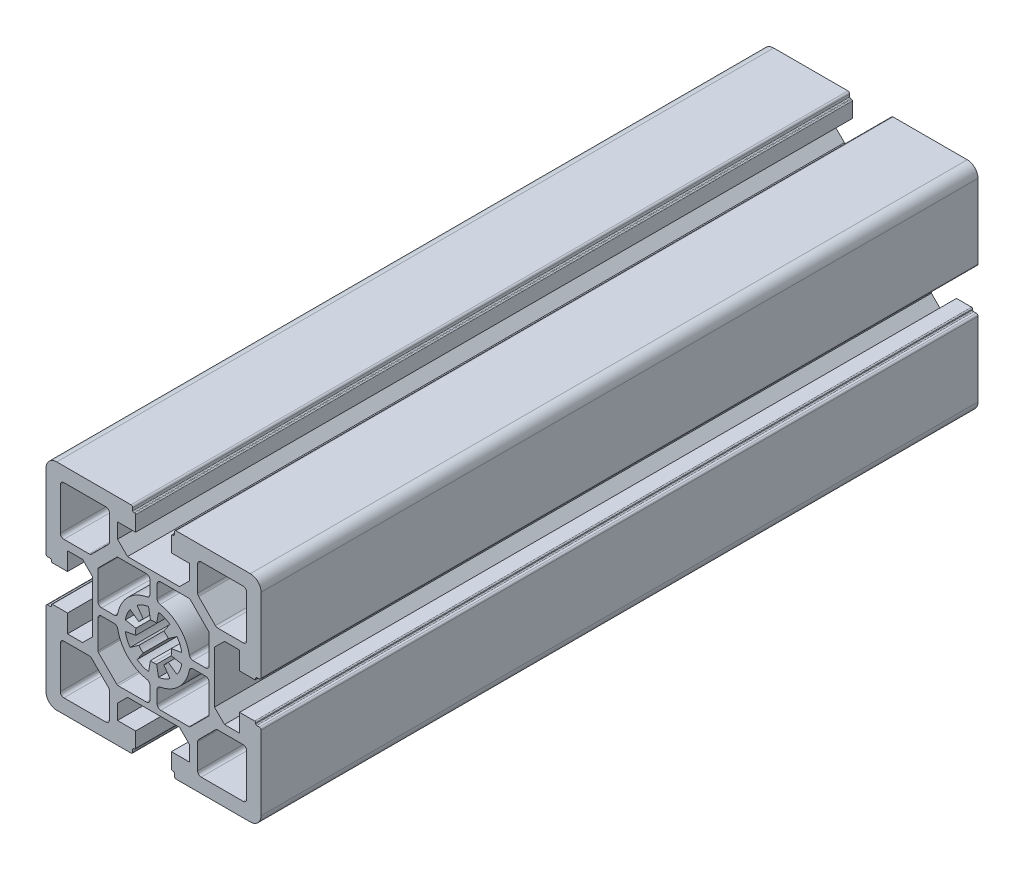
from build123d import *

# Parameters (mm, degrees)
BASE_EXTRUDE_DEPTH = 200


with BuildPart() as part:
    # Sketch1 → Base-Extrude (new body)
    with BuildSketch(Plane.XY):
        with BuildLine():
            Line((7.24997588, 17.000014817), (-2.412e-05, 17.000014817))
            Line((-2.412e-05, 17.000014817), (-7.25002412, 17.000014817))
            Line((-7.25002412, 17.000014817), (-10.05002512, 19.800013819))
            Line((-10.05002512, 19.800013819), (-10.05002512, 24.000014819))
            Line((-10.05002512, 24.000014819), (-5.00002412, 24.000014819))
            Line((-5.00002412, 24.000014819), (-5.00002412, 28.200020635))
            ThreePointArc((-5.00002412, 28.200020635), (-5.087890425, 28.412148621), (-5.300018455, 28.500014819))
            Line((-5.300018455, 28.500014819), (-5.500021455, 28.500014819))
            ThreePointArc((-5.500021455, 28.500014819), (-5.712152769, 28.587882347), (-5.800020455, 28.800013596))
            Line((-5.800020455, 28.800013596), (-5.800020455, 29.500015192))
            ThreePointArc((-5.800020455, 29.500015192), (-5.946466955, 29.853568318), (-6.300020081, 30.000014817))
            Line((-6.300020081, 30.000014817), (-27.000022696, 30.000014817))
            ThreePointArc((-27.000022696, 30.000014817), (-29.121341455, 29.121335817), (-30.000020455, 27.000017059))
            Line((-30.000020455, 27.000017059), (-30.000020455, 6.300013444))
            ThreePointArc((-30.000020455, 6.300013444), (-29.853573955, 5.946460317), (-29.500020828, 5.800013817))
            Line((-29.500020828, 5.800013817), (-28.800019731, 5.800013817))
            ThreePointArc((-28.800019731, 5.800013817), (-28.587888208, 5.712146064), (-28.500020455, 5.500014542))
            Line((-28.500020455, 5.500014542), (-28.500020455, 5.300014093))
            ThreePointArc((-28.500020455, 5.300014093), (-28.412152701, 5.087882571), (-28.200021179, 5.000014817))
            Line((-28.200021179, 5.000014817), (-24.000020455, 5.000014817))
            Line((-24.000020455, 5.000014817), (-24.000020455, 10.050012866))
            Line((-24.000020455, 10.050012866), (-19.800019665, 10.050012866))
            Line((-19.800019665, 10.050012866), (-17.000019665, 7.250013866))
            Line((-17.000019665, 7.250013866), (-17.000019665, 4.3167e-05))
            Line((-17.000019665, 4.3167e-05), (-17.000019665, -7.249956831))
            Line((-17.000019665, -7.249956831), (-19.800019665, -10.049955831))
            Line((-19.800019665, -10.049955831), (-24.000020455, -10.049955831))
            Line((-24.000020455, -10.049955831), (-24.000020455, -4.999957783))
            Line((-24.000020455, -4.999957783), (-28.200021179, -4.999957783))
            ThreePointArc((-28.200021179, -4.999957783), (-28.412152701, -5.087825536), (-28.500020455, -5.299957058))
            Line((-28.500020455, -5.299957058), (-28.500020455, -5.499957507))
            ThreePointArc((-28.500020455, -5.499957507), (-28.587888208, -5.712089029), (-28.800019731, -5.799956783))
            Line((-28.800019731, -5.799956783), (-29.500020828, -5.799956783))
            ThreePointArc((-29.500020828, -5.799956783), (-29.853573955, -5.946403283), (-30.000020455, -6.299956409))
            Line((-30.000020455, -6.299956409), (-30.000020455, -26.999960024))
            ThreePointArc((-30.000020455, -26.999960024), (-29.121341455, -29.121278783), (-27.000022696, -29.999957783))
            Line((-27.000022696, -29.999957783), (-6.300020081, -29.999957783))
            ThreePointArc((-6.300020081, -29.999957783), (-5.946466955, -29.853511283), (-5.800020455, -29.499958157))
            Line((-5.800020455, -29.499958157), (-5.800020455, -28.799956561))
            ThreePointArc((-5.800020455, -28.799956561), (-5.712152769, -28.587825312), (-5.500021455, -28.499957784))
            Line((-5.500021455, -28.499957784), (-5.300018455, -28.499957784))
            ThreePointArc((-5.300018455, -28.499957784), (-5.087890425, -28.412091586), (-5.00002412, -28.199963601))
            Line((-5.00002412, -28.199963601), (-5.00002412, -23.999957784))
            Line((-5.00002412, -23.999957784), (-10.05002512, -23.999957784))
            Line((-10.05002512, -23.999957784), (-10.05002512, -19.799956784))
            Line((-10.05002512, -19.799956784), (-7.25002412, -16.999957783))
            Line((-7.25002412, -16.999957783), (-2.412e-05, -16.999957783))
            Line((-2.412e-05, -16.999957783), (7.24997588, -16.999957783))
            Line((7.24997588, -16.999957783), (10.04997688, -19.799956784))
            Line((10.04997688, -19.799956784), (10.04997688, -23.999957784))
            Line((10.04997688, -23.999957784), (4.99997588, -23.999957784))
            Line((4.99997588, -23.999957784), (4.99997588, -28.199963601))
            ThreePointArc((4.99997588, -28.199963601), (5.087842185, -28.412091586), (5.299970215, -28.499957784))
            Line((5.299970215, -28.499957784), (5.499973215, -28.499957784))
            ThreePointArc((5.499973215, -28.499957784), (5.71210453, -28.587825312), (5.799972216, -28.799956561))
            Line((5.799972216, -28.799956561), (5.799972216, -29.499958157))
            ThreePointArc((5.799972216, -29.499958157), (5.946418716, -29.853511283), (6.299971842, -29.999957783))
            Line((6.299971842, -29.999957783), (26.999974457, -29.999957783))
            ThreePointArc((26.999974457, -29.999957783), (29.121293215, -29.121278783), (29.999972215, -26.999960024))
            Line((29.999972215, -26.999960024), (29.999972215, -6.299956409))
            ThreePointArc((29.999972215, -6.299956409), (29.853525715, -5.946403283), (29.499972589, -5.799956783))
            Line((29.499972589, -5.799956783), (28.799971491, -5.799956783))
            ThreePointArc((28.799971491, -5.799956783), (28.587839969, -5.712089029), (28.499972215, -5.499957507))
            Line((28.499972215, -5.499957507), (28.499972215, -5.299957058))
            ThreePointArc((28.499972215, -5.299957058), (28.412104462, -5.087825536), (28.199972939, -4.999957783))
            Line((28.199972939, -4.999957783), (23.999972215, -4.999957783))
            Line((23.999972215, -4.999957783), (23.999972215, -10.049955831))
            Line((23.999972215, -10.049955831), (19.799971426, -10.049955831))
            Line((19.799971426, -10.049955831), (16.999971426, -7.249956831))
            Line((16.999971426, -7.249956831), (16.999971426, 4.3167e-05))
            Line((16.999971426, 4.3167e-05), (16.999971426, 7.250013866))
            Line((16.999971426, 7.250013866), (19.799971426, 10.050012866))
            Line((19.799971426, 10.050012866), (23.999972215, 10.050012866))
            Line((23.999972215, 10.050012866), (23.999972215, 5.000014817))
            Line((23.999972215, 5.000014817), (28.199972939, 5.000014817))
            ThreePointArc((28.199972939, 5.000014817), (28.412104462, 5.087882571), (28.499972215, 5.300014093))
            Line((28.499972215, 5.300014093), (28.499972215, 5.500014542))
            ThreePointArc((28.499972215, 5.500014542), (28.587839969, 5.712146064), (28.799971491, 5.800013817))
            Line((28.799971491, 5.800013817), (29.499972589, 5.800013817))
            ThreePointArc((29.499972589, 5.800013817), (29.853525715, 5.946460317), (29.999972215, 6.300013444))
            Line((29.999972215, 6.300013444), (29.999972215, 27.000017059))
            ThreePointArc((29.999972215, 27.000017059), (29.121293215, 29.121335817), (26.999974457, 30.000014817))
            Line((26.999974457, 30.000014817), (6.299971842, 30.000014817))
            ThreePointArc((6.299971842, 30.000014817), (5.946418716, 29.853568318), (5.799972216, 29.500015192))
            Line((5.799972216, 29.500015192), (5.799972216, 28.800013596))
            ThreePointArc((5.799972216, 28.800013596), (5.71210453, 28.587882347), (5.499973215, 28.500014819))
            Line((5.499973215, 28.500014819), (5.299970215, 28.500014819))
            ThreePointArc((5.299970215, 28.500014819), (5.087842185, 28.412148621), (4.99997588, 28.200020635))
            Line((4.99997588, 28.200020635), (4.99997588, 24.000014819))
            Line((4.99997588, 24.000014819), (10.04997688, 24.000014819))
            Line((10.04997688, 24.000014819), (10.04997688, 19.800013819))
            Line((10.04997688, 19.800013819), (7.24997588, 17.000014817))
        make_face()
        with BuildLine():
            Line((24.999970687, 12.300015508), (17.964182773, 12.300015508))
            ThreePointArc((17.964182773, 12.300015508), (17.581498992, 12.376136067), (17.257075378, 12.59290907))
            Line((17.257075378, 12.59290907), (12.592863552, 17.257122896))
            ThreePointArc((12.592863552, 17.257122896), (12.376090508, 17.581546796), (12.29996994, 17.964230842))
            Line((12.29996994, 17.964230842), (12.29996994, 25.000017255))
            ThreePointArc((12.29996994, 25.000017255), (12.59286294, 25.707123508), (13.299969193, 26.000016508))
            Line((13.299969193, 26.000016508), (24.999970687, 26.000016508))
            ThreePointArc((24.999970687, 26.000016508), (25.70707694, 25.707123508), (25.99996994, 25.000017255))
            Line((25.99996994, 25.000017255), (25.99996994, 13.300014761))
            ThreePointArc((25.99996994, 13.300014761), (25.70707694, 12.592908508), (24.999970687, 12.300015508))
        make_face(mode=Mode.SUBTRACT)
        with BuildLine():
            Line((-0.868254781, 4.924047323), (-1.389203942, 7.878492919))
            ThreePointArc((-1.389203942, 7.878492919), (-3.061491097, 7.391065963), (-4.588639176, 6.553242527))
            Line((-4.588639176, 6.553242527), (-2.867900032, 4.095774325))
            ThreePointArc((-2.867900032, 4.095774325), (-3.535545186, 3.535556326), (-4.095767305, 2.867914629))
            Line((-4.095767305, 2.867914629), (-6.553231573, 4.588649719))
            ThreePointArc((-6.553231573, 4.588649719), (-7.391053065, 3.061505388), (-7.878479822, 1.389222571))
            Line((-7.878479822, 1.389222571), (-4.924052211, 0.868276934))
            ThreePointArc((-4.924052211, 0.868276934), (-5.000015145, 2.8517e-05), (-4.924052211, -0.8682199))
            Line((-4.924052211, -0.8682199), (-7.878479822, -1.389165536))
            ThreePointArc((-7.878479822, -1.389165536), (-7.391053065, -3.061448353), (-6.553231573, -4.588592684))
            Line((-6.553231573, -4.588592684), (-4.095767305, -2.867857594))
            ThreePointArc((-4.095767305, -2.867857594), (-3.535545186, -3.535499291), (-2.867900032, -4.09571729))
            Line((-2.867900032, -4.09571729), (-4.588639176, -6.553185492))
            ThreePointArc((-4.588639176, -6.553185492), (-3.061491097, -7.391008929), (-1.389203942, -7.878435884))
            Line((-1.389203942, -7.878435884), (-0.868254781, -4.923990288))
            ThreePointArc((-0.868254781, -4.923990288), (-0.435797618, -4.980922606), (-2.412e-05, -4.999947433))
            ThreePointArc((-2.412e-05, -4.999947433), (0.435749379, -4.980922606), (0.868206541, -4.923990288))
            Line((0.868206541, -4.923990288), (1.389155702, -7.878435884))
            ThreePointArc((1.389155702, -7.878435884), (3.061442857, -7.391008929), (4.588590936, -6.553185492))
            Line((4.588590936, -6.553185492), (2.867851793, -4.09571729))
            ThreePointArc((2.867851793, -4.09571729), (3.535496947, -3.535499291), (4.095719065, -2.867857594))
            Line((4.095719065, -2.867857594), (6.553183334, -4.588592684))
            ThreePointArc((6.553183334, -4.588592684), (7.391004826, -3.061448353), (7.878431582, -1.389165536))
            Line((7.878431582, -1.389165536), (4.924003972, -0.8682199))
            ThreePointArc((4.924003972, -0.8682199), (4.999966905, 2.8517e-05), (4.924003972, 0.868276934))
            Line((4.924003972, 0.868276934), (7.878431582, 1.389222571))
            ThreePointArc((7.878431582, 1.389222571), (7.391004826, 3.061505388), (6.553183334, 4.588649719))
            Line((6.553183334, 4.588649719), (4.095719065, 2.867914629))
            ThreePointArc((4.095719065, 2.867914629), (3.535496947, 3.535556326), (2.867851793, 4.095774325))
            Line((2.867851793, 4.095774325), (4.588590936, 6.553242527))
            ThreePointArc((4.588590936, 6.553242527), (3.061442857, 7.391065963), (1.389155702, 7.878492919))
            Line((1.389155702, 7.878492919), (0.868206541, 4.924047323))
            ThreePointArc((0.868206541, 4.924047323), (0.435749379, 4.980979641), (-2.412e-05, 5.000004467))
            ThreePointArc((-2.412e-05, 5.000004467), (-0.435797618, 4.980979641), (-0.868254781, 4.924047323))
        make_face(mode=Mode.SUBTRACT)
        with BuildLine():
            Line((14.499970687, 1.000016508), (10.969128525, 1.000016508))
            ThreePointArc((10.969128525, 1.000016508), (10.328572063, 1.232105996), (9.985348997, 1.820643198))
            ThreePointArc((9.985348997, 1.820643198), (7.177103386, 7.177150109), (1.820595849, 9.985394525))
            ThreePointArc((1.820595849, 9.985394525), (1.232058499, 10.328617545), (0.99996894, 10.969174093))
            Line((0.99996894, 10.969174093), (0.99996894, 14.500017255))
            ThreePointArc((0.99996894, 14.500017255), (1.29286194, 15.207123508), (1.999968193, 15.500016508))
            Line((1.999968193, 15.500016508), (9.900222627, 15.500016508))
            ThreePointArc((9.900222627, 15.500016508), (10.091564812, 15.461956186), (10.253776891, 15.353569557))
            Line((10.253776891, 15.353569557), (15.35352292, 10.253824528))
            ThreePointArc((15.35352292, 10.253824528), (15.461909599, 10.091612425), (15.49996994, 9.900270195))
            Line((15.49996994, 9.900270195), (15.49996994, 2.000015761))
            ThreePointArc((15.49996994, 2.000015761), (15.20707694, 1.292909508), (14.499970687, 1.000016508))
        make_face(mode=Mode.SUBTRACT)
        with BuildLine():
            Line((-25.000018927, -12.299958473), (-17.964231013, -12.299958473))
            ThreePointArc((-17.964231013, -12.299958473), (-17.581547231, -12.376079032), (-17.257123618, -12.592852035))
            Line((-17.257123618, -12.592852035), (-12.592911792, -17.257065861))
            ThreePointArc((-12.592911792, -17.257065861), (-12.376138748, -17.581489761), (-12.30001818, -17.964173807))
            Line((-12.30001818, -17.964173807), (-12.30001818, -24.99996022))
            ThreePointArc((-12.30001818, -24.99996022), (-12.59291118, -25.707066473), (-13.300017432, -25.999959473))
            Line((-13.300017432, -25.999959473), (-25.000018927, -25.999959473))
            ThreePointArc((-25.000018927, -25.999959473), (-25.70712518, -25.707066473), (-26.00001818, -24.99996022))
            Line((-26.00001818, -24.99996022), (-26.00001818, -13.299957726))
            ThreePointArc((-26.00001818, -13.299957726), (-25.70712518, -12.592851473), (-25.000018927, -12.299958473))
        make_face(mode=Mode.SUBTRACT)
        with BuildLine():
            Line((-14.500018927, -0.999959473), (-10.969176764, -0.999959473))
            ThreePointArc((-10.969176764, -0.999959473), (-10.328620302, -1.232048961), (-9.985397236, -1.820586163))
            ThreePointArc((-9.985397236, -1.820586163), (-7.177151626, -7.177093074), (-1.820644088, -9.98533749))
            ThreePointArc((-1.820644088, -9.98533749), (-1.232106738, -10.32856051), (-1.000017179, -10.969117058))
            Line((-1.000017179, -10.969117058), (-1.000017179, -14.49996022))
            ThreePointArc((-1.000017179, -14.49996022), (-1.292910179, -15.207066473), (-2.000016432, -15.499959473))
            Line((-2.000016432, -15.499959473), (-9.900270867, -15.499959473))
            ThreePointArc((-9.900270867, -15.499959473), (-10.091613052, -15.461899151), (-10.253825131, -15.353512522))
            Line((-10.253825131, -15.353512522), (-15.353571159, -10.253767494))
            ThreePointArc((-15.353571159, -10.253767494), (-15.461957839, -10.091555391), (-15.50001818, -9.90021316))
            Line((-15.50001818, -9.90021316), (-15.50001818, -1.999958726))
            ThreePointArc((-15.50001818, -1.999958726), (-15.20712518, -1.292852473), (-14.500018927, -0.999959473))
        make_face(mode=Mode.SUBTRACT)
        with BuildLine():
            Line((0.99996894, -10.969117058), (0.99996894, -14.49996022))
            ThreePointArc((0.99996894, -14.49996022), (1.29286194, -15.207066473), (1.999968193, -15.499959473))
            Line((1.999968193, -15.499959473), (9.900222627, -15.499959473))
            ThreePointArc((9.900222627, -15.499959473), (10.091564812, -15.461899151), (10.253776891, -15.353512522))
            Line((10.253776891, -15.353512522), (15.35352292, -10.253767494))
            ThreePointArc((15.35352292, -10.253767494), (15.461909599, -10.091555391), (15.49996994, -9.90021316))
            Line((15.49996994, -9.90021316), (15.49996994, -1.999958726))
            ThreePointArc((15.49996994, -1.999958726), (15.20707694, -1.292852473), (14.499970687, -0.999959473))
            Line((14.499970687, -0.999959473), (10.969128525, -0.999959473))
            ThreePointArc((10.969128525, -0.999959473), (10.328572063, -1.232048961), (9.985348997, -1.820586163))
            ThreePointArc((9.985348997, -1.820586163), (7.177103386, -7.177093074), (1.820595849, -9.98533749))
            ThreePointArc((1.820595849, -9.98533749), (1.232058499, -10.32856051), (0.99996894, -10.969117058))
        make_face(mode=Mode.SUBTRACT)
        with BuildLine():
            Line((-1.000017179, 10.969174093), (-1.000017179, 14.500017255))
            ThreePointArc((-1.000017179, 14.500017255), (-1.292910179, 15.207123508), (-2.000016432, 15.500016508))
            Line((-2.000016432, 15.500016508), (-9.900270867, 15.500016508))
            ThreePointArc((-9.900270867, 15.500016508), (-10.091613052, 15.461956186), (-10.253825131, 15.353569557))
            Line((-10.253825131, 15.353569557), (-15.353571159, 10.253824528))
            ThreePointArc((-15.353571159, 10.253824528), (-15.461957839, 10.091612425), (-15.50001818, 9.900270195))
            Line((-15.50001818, 9.900270195), (-15.50001818, 2.000015761))
            ThreePointArc((-15.50001818, 2.000015761), (-15.20712518, 1.292909508), (-14.500018927, 1.000016508))
            Line((-14.500018927, 1.000016508), (-10.969176764, 1.000016508))
            ThreePointArc((-10.969176764, 1.000016508), (-10.328620302, 1.232105996), (-9.985397236, 1.820643198))
            ThreePointArc((-9.985397236, 1.820643198), (-7.177151626, 7.177150109), (-1.820644088, 9.985394525))
            ThreePointArc((-1.820644088, 9.985394525), (-1.232106738, 10.328617545), (-1.000017179, 10.969174093))
        make_face(mode=Mode.SUBTRACT)
        with BuildLine():
            Line((-26.00001818, 13.300014761), (-26.00001818, 25.000017255))
            ThreePointArc((-26.00001818, 25.000017255), (-25.70712518, 25.707123508), (-25.000018927, 26.000016508))
            Line((-25.000018927, 26.000016508), (-13.300017432, 26.000016508))
            ThreePointArc((-13.300017432, 26.000016508), (-12.59291118, 25.707123508), (-12.30001818, 25.000017255))
            Line((-12.30001818, 25.000017255), (-12.30001818, 17.964230842))
            ThreePointArc((-12.30001818, 17.964230842), (-12.376138748, 17.581546796), (-12.592911792, 17.257122896))
            Line((-12.592911792, 17.257122896), (-17.257123618, 12.59290907))
            ThreePointArc((-17.257123618, 12.59290907), (-17.581547231, 12.376136067), (-17.964231013, 12.300015508))
            Line((-17.964231013, 12.300015508), (-25.000018927, 12.300015508))
            ThreePointArc((-25.000018927, 12.300015508), (-25.70712518, 12.592908508), (-26.00001818, 13.300014761))
        make_face(mode=Mode.SUBTRACT)
        with BuildLine():
            Line((25.99996994, -13.299957726), (25.99996994, -24.99996022))
            ThreePointArc((25.99996994, -24.99996022), (25.70707694, -25.707066473), (24.999970687, -25.999959473))
            Line((24.999970687, -25.999959473), (13.299969193, -25.999959473))
            ThreePointArc((13.299969193, -25.999959473), (12.59286294, -25.707066473), (12.29996994, -24.99996022))
            Line((12.29996994, -24.99996022), (12.29996994, -17.964173807))
            ThreePointArc((12.29996994, -17.964173807), (12.376090508, -17.581489761), (12.592863552, -17.257065861))
            Line((12.592863552, -17.257065861), (17.257075378, -12.592852035))
            ThreePointArc((17.257075378, -12.592852035), (17.581498992, -12.376079032), (17.964182773, -12.299958473))
            Line((17.964182773, -12.299958473), (24.999970687, -12.299958473))
            ThreePointArc((24.999970687, -12.299958473), (25.70707694, -12.592851473), (25.99996994, -13.299957726))
        make_face(mode=Mode.SUBTRACT)
    extrude(amount=-BASE_EXTRUDE_DEPTH)


solid = part.part
